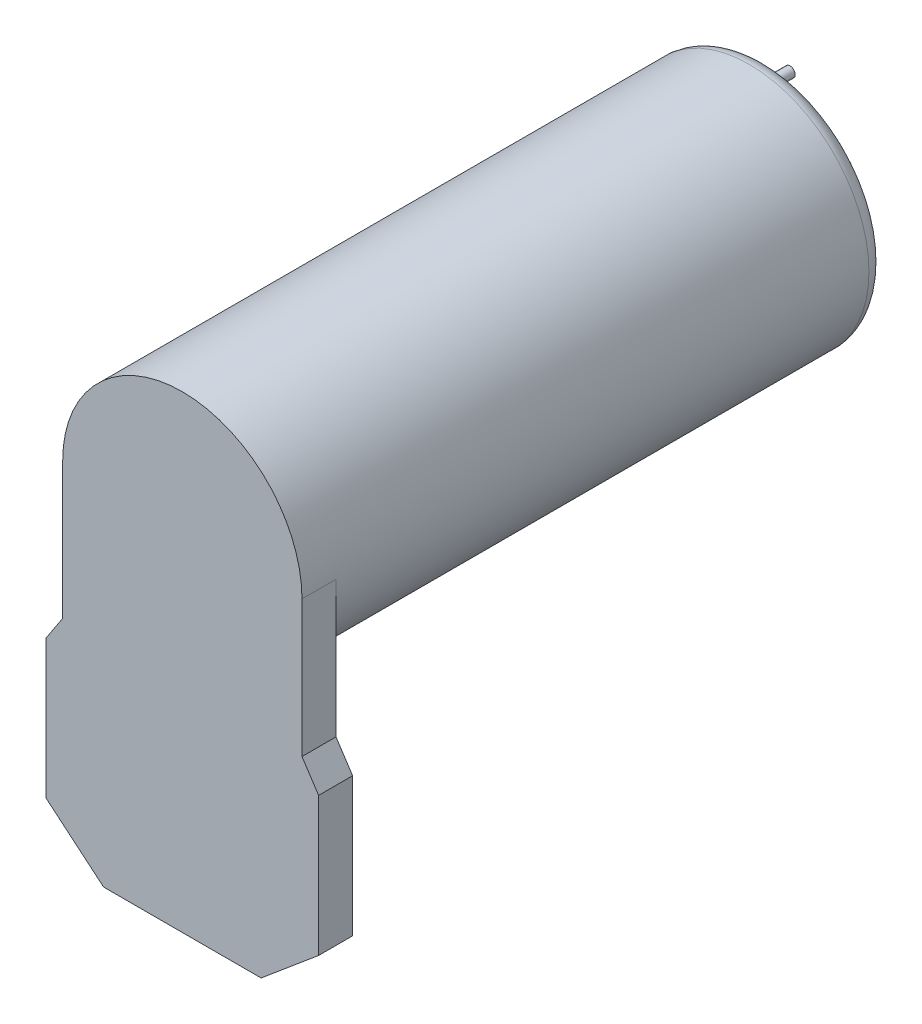
from build123d import *
from build123d.topology import SkipClean

# Parameters (mm, degrees)
BODY_DEPTH         = 5
SKETCH4_R          = 2.5
TOP_ELECTRIC_DEPTH = 1
SKETCH6_R          = 0.75
CABLE_DEPTH        = 7.5


with BuildPart() as part:
    # Sketch1 → Body (new body)
    with BuildSketch(Plane.XY.offset(125.3)):
        with BuildLine():
            Line((-20.05, 9), (-17.6, 12.720551034))
            Line((-17.6, 12.720551034), (-17.6, 32.8))
            ThreePointArc((-17.6, 32.8), (-12.445079349, 45.245079349), (0, 50.4))
            ThreePointArc((0, 50.4), (12.445079349, 45.245079349), (17.6, 32.8))
            Line((17.6, 32.8), (17.6, 12.720551034))
            Line((17.6, 12.720551034), (20.05, 9))
            Line((20.05, 9), (20.05, 0))
            Line((20.05, 0), (20.05, -11.4))
            Line((20.05, -11.4), (11.588549493, -18.5))
            Line((11.588549493, -18.5), (7.016550666, -18.5))
            Line((7.016550666, -18.5), (-7.016550666, -18.5))
            Line((-7.016550666, -18.5), (-11.588549493, -18.5))
            Line((-11.588549493, -18.5), (-20.05, -11.4))
            Line((-20.05, -11.4), (-20.05, 0))
            Line((-20.05, 0), (-20.05, 9))
        make_face()
    extrude(amount=BODY_DEPTH)

    # Sketch3 → Motor-Body (revolve)
    with SkipClean():  # keep this step's faces unmerged: merging them makes the solid invalid here
        with BuildSketch(Plane(origin=(0, 0, 0), x_dir=(0, 0, -1), z_dir=(1, 0, 0)), mode=Mode.PRIVATE) as motor_body_sk:
            with BuildLine():
                Line((-125.3, 32.8), (-40.4, 32.8))
                Line((-40.4, 32.8), (-40.4, 36.490598923))
                Line((-40.4, 36.490598923), (-44.4, 38.8))
                Line((-44.4, 38.8), (-44.4, 47.9))
                ThreePointArc((-44.4, 47.9), (-45.132233047, 49.667766953), (-46.9, 50.4))
                Line((-46.9, 50.4), (-125.3, 50.4))
                Line((-125.3, 50.4), (-125.3, 32.8))
            make_face()
        revolve(motor_body_sk.sketch.rotate(Axis((0, 32.8, 140.3), (0, 0, -1)), 90), axis=Axis((0, 32.8, 140.3), (0, 0, -1)))  # turned: the seam where the file's is

    # Sketch4 → Top-Electric (add)
    with SkipClean():  # keep this step's faces unmerged: merging them makes the solid invalid here
        with BuildSketch(Plane(origin=(0, 0, 44.4), x_dir=(-1, 0, 0), z_dir=(0, 0, -1))):
            with Locations(Location((9.84807753, 31.063518223, 0), (0, 0, 180))):  # turned: the seam where the file's is
                Circle(SKETCH4_R)
            with Locations(Location((5, 41.460254038, 0), (0, 0, 180))):  # turned: the seam where the file's is
                Circle(SKETCH4_R)
        extrude(amount=TOP_ELECTRIC_DEPTH)

    # Sketch6 → Cable (add)
    with SkipClean():  # keep this step's faces unmerged: merging them makes the solid invalid here
        with BuildSketch(Plane(origin=(0, 0, 43.4), x_dir=(-1, 0, 0), z_dir=(0, 0, -1))):
            with Locations((5, 41.460254038)):
                Circle(SKETCH6_R)
            with Locations((9.84807753, 31.063518223)):
                Circle(SKETCH6_R)
        extrude(amount=CABLE_DEPTH)


solid = part.part
